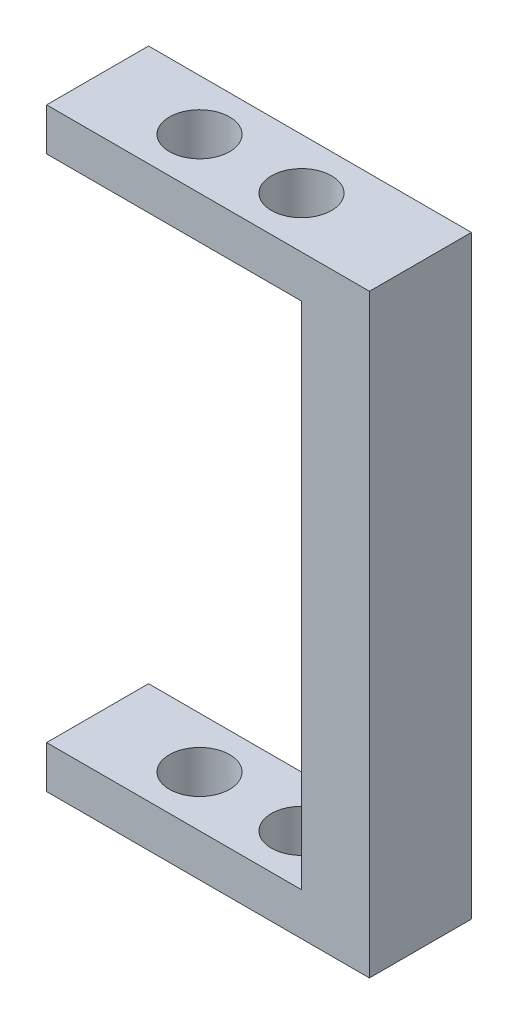
from build123d import *

# Parameters (mm, degrees)
SKETCH1_W            = 19.05
SKETCH1_H            = 3.175
SKETCH1_W_2          = 5.08
SKETCH1_H_2          = 44.45
BOSS_EXTRUDE1_DEPTH  = 7.62
M4_CLEARANCE_HOLE1_D = 4.5


with BuildPart() as part:
    # Sketch1 → Boss-Extrude1 (new body)
    with BuildSketch(Plane.XY):
        with Locations((-12.065, 20.6375)):
            Rectangle(SKETCH1_W, SKETCH1_H)
        Rectangle(SKETCH1_W_2, SKETCH1_H_2)
        with Locations((-12.065, -20.6375)):
            Rectangle(SKETCH1_W, SKETCH1_H)
    extrude(amount=BOSS_EXTRUDE1_DEPTH)

    # M4 Clearance Hole1 (through all)
    with Locations(Plane(origin=(0, 22.225, 0), x_dir=(1, 0, 0), z_dir=(0, 1, 0))):
        with Locations((-13.97, -3.81), (-6.35, -3.81)):
            Hole(M4_CLEARANCE_HOLE1_D / 2)


solid = part.part
